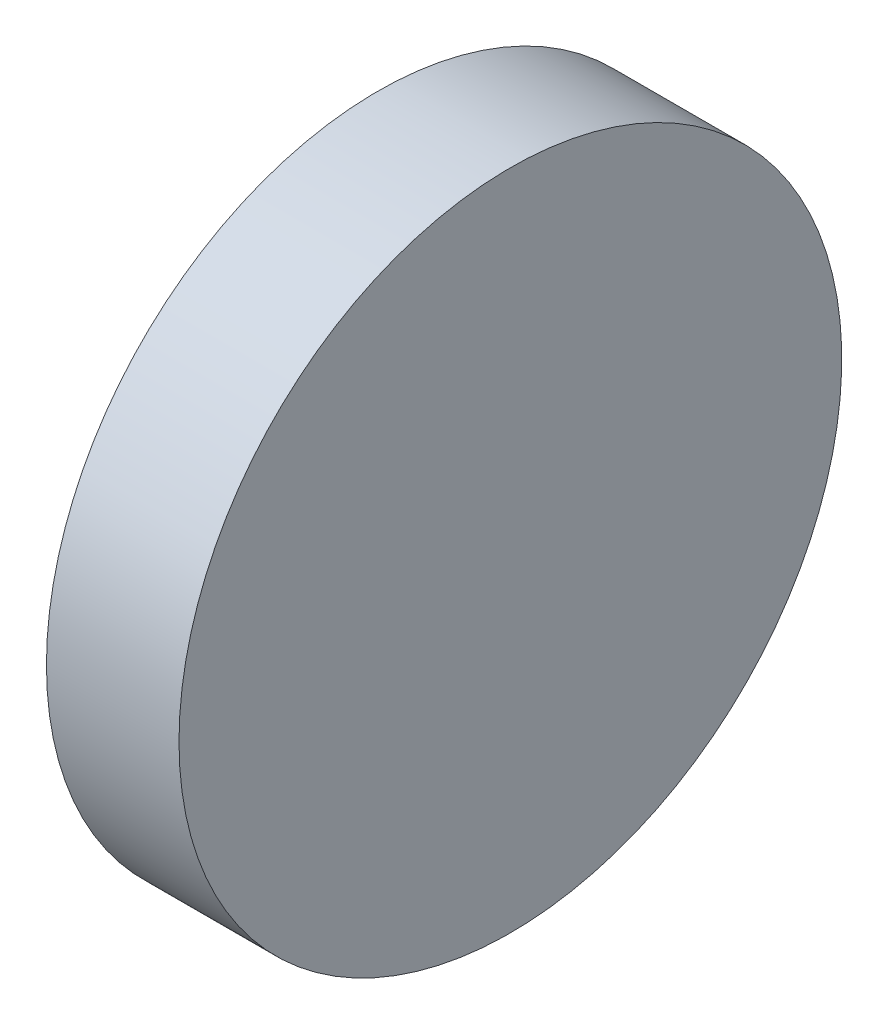
from build123d import *

# Parameters (mm, degrees)
SKETCH_1_W = 10
SKETCH_1_H = 25


with BuildPart() as part:
    # 草图1 → 旋转1 (revolve)
    with BuildSketch(Plane.XY, mode=Mode.PRIVATE) as revolve_1_sk:
        with Locations((525.314280985, 167.086358698)):
            Rectangle(SKETCH_1_W, SKETCH_1_H)
    revolve(revolve_1_sk.sketch.rotate(Axis((508.001603985, 154.586358698, 0), (1, 0, 0)), 90), axis=Axis((508.001603985, 154.586358698, 0), (1, 0, 0)))  # turned: the seam where the file's is


solid = part.part
